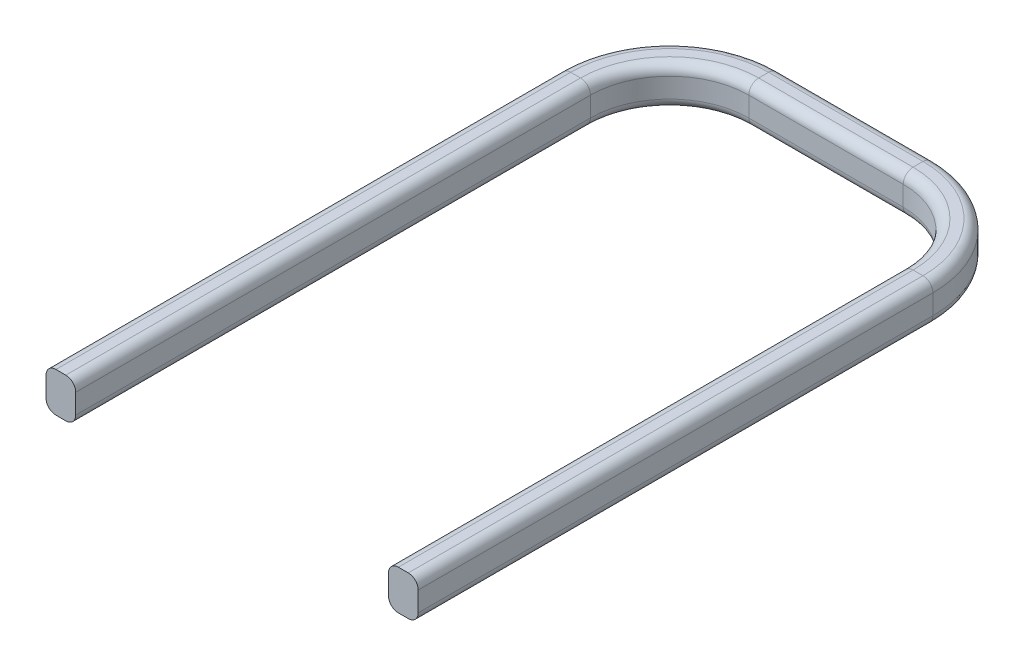
from build123d import *

# Parameters (mm, degrees)
SKETCH3_W = 0.75
SKETCH3_H = 1
FILLET1_R = 0.25


with BuildPart() as part:
    # Sweep1: sweep along a path in Sketch2
    with BuildLine(Plane(origin=(0, 0, 0), x_dir=(1, 0, 0), z_dir=(0, 1, 0))) as sweep1_path:
        Line((-3.95, 0), (-3.95, 13))
        ThreePointArc((-3.95, 13), (-3.364213562, 14.414213562), (-1.95, 15))
        Line((-1.95, 15), (1.95, 15))
        ThreePointArc((1.95, 15), (3.364213562, 14.414213562), (3.95, 13))
        Line((3.95, 13), (3.95, 0))
    # Sketch3 → Sweep1 (sweep)
    with BuildSketch(Plane.XY):
        with Locations((-4.325, 0.5)):
            Rectangle(SKETCH3_W, SKETCH3_H)
    sweep(path=sweep1_path.line)

    # Fillet1
    fillet1_edges = [part.edges().sort_by_distance(p)[0] for p in [
        (-3.95, 1, -6.5),
        (-4.7, 1, -6.5),
        (-4.7, 0, -6.5),
        (3.95, 0, -6.5),
        (3.95, 1, -6.5),
        (4.7, 1, -6.5),
        (4.7, 0, -6.5),
        (3.364213562, 0, -14.414213562),
        (3.364213562, 1, -14.414213562),
        (3.894543648, 1, -14.944543648),
        (3.894543648, 0, -14.944543648),
        (0, 0, -15),
        (0, 1, -15),
        (0, 1, -15.75),
        (0, 0, -15.75),
        (-3.364213562, 0, -14.414213562),
        (-3.364213562, 1, -14.414213562),
        (-3.894543648, 1, -14.944543648),
        (-3.894543648, 0, -14.944543648),
        (-3.95, 0, -6.5),
    ]]
    fillet(fillet1_edges, radius=FILLET1_R)


solid = part.part
